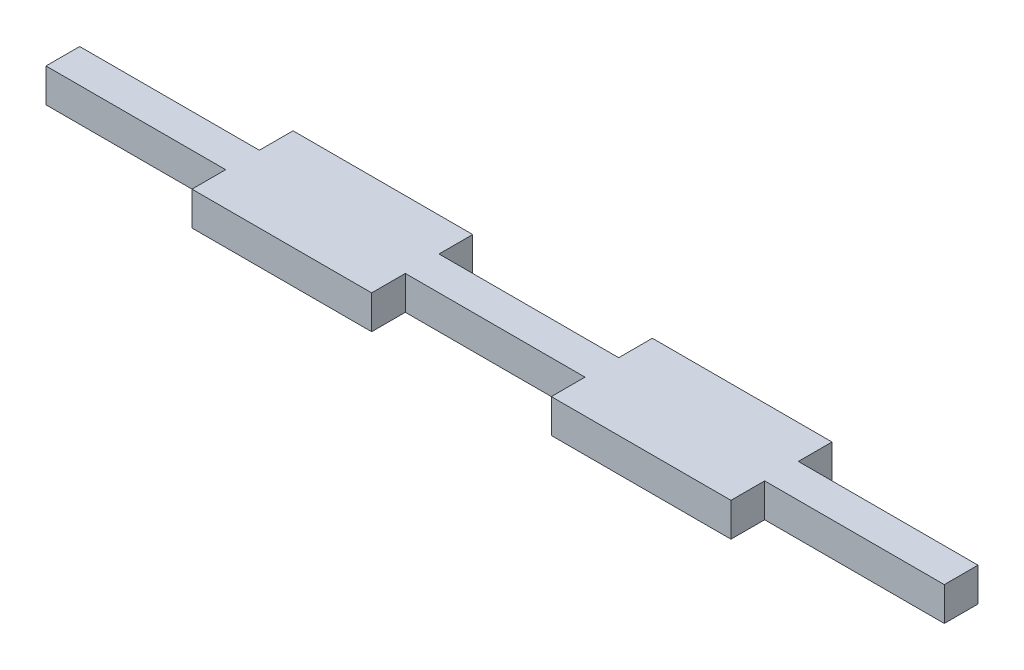
from build123d import *

# Parameters (mm, degrees)
BOSS_EXTRUDE2_DEPTH = 3


with BuildPart() as part:
    # Sketch1 → Boss-Extrude2 (new body)
    with BuildSketch(Plane(origin=(0, 0, 0), x_dir=(1, 0, 0), z_dir=(0, 1, 0))):
        Polygon((-24, -4.5), (-8, -4.5), (-8, -1.5), (8, -1.5), (8, -4.5), (24, -4.5), (24, -1.5), (40, -1.5), (40, 1.5), (24, 1.5), (24, 4.5), (8, 4.5), (8, 1.5), (-8, 1.5), (-8, 4.5), (-24, 4.5), (-24, 1.5), (-40, 1.5), (-40, -1.5), (-24, -1.5), align=None)
    extrude(amount=BOSS_EXTRUDE2_DEPTH)


solid = part.part
